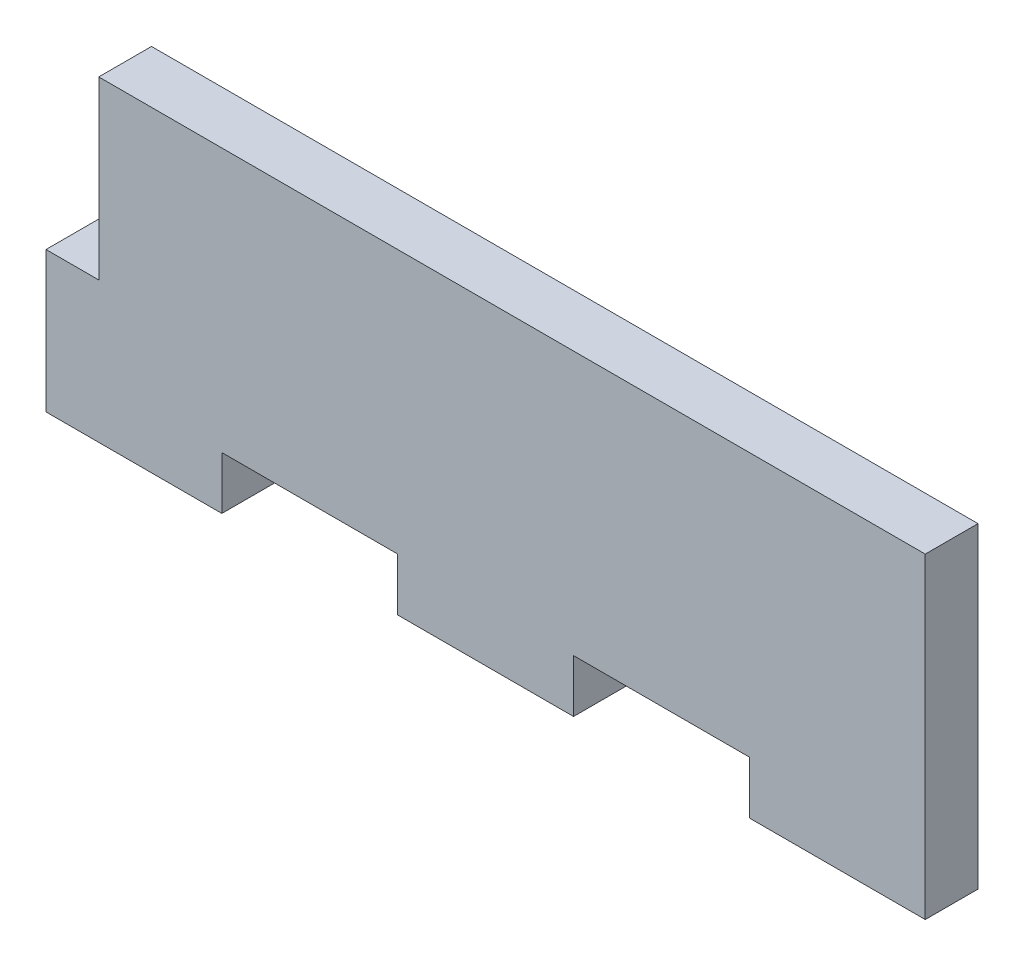
from build123d import *

# Parameters (mm, degrees)
ESQUISSE1_W                = 50
ESQUISSE1_H                = 18
BOSS_EXTRU_1_DEPTH         = 3
ESQUISSE2_W                = 10
ESQUISSE2_H                = 3
ENL_V_MAT_EXTRU_1_DEPTH    = 3
R_P_TITION_LIN_AIRE1_COUNT = 2
R_P_TITION_LIN_AIRE1_PITCH = 20
ESQUISSE3_W                = 3
ESQUISSE3_H                = 10
ENL_V_MAT_EXTRU_2_DEPTH    = 3


with BuildPart() as part:
    # Esquisse1 → Boss.-Extru.1 (new body)
    with BuildSketch(Plane.XY):
        with Locations((25, -9)):
            Rectangle(ESQUISSE1_W, ESQUISSE1_H)
    extrude(amount=BOSS_EXTRU_1_DEPTH)

    # Esquisse2 → Enlèv. mat.-Extru.1 (cut)
    with BuildSketch(Plane.XY.offset(3)):
        with Locations((35, -16.5)):
            Rectangle(ESQUISSE2_W, ESQUISSE2_H)
    enl_v_mat_extru_1 = extrude(amount=-ENL_V_MAT_EXTRU_1_DEPTH, mode=Mode.SUBTRACT)

    # Répétition linéaire1: Enlèv. mat.-Extru.1 ×2
    with Locations(*[(-i * R_P_TITION_LIN_AIRE1_PITCH, 0, 0) for i in range(1, R_P_TITION_LIN_AIRE1_COUNT)]):
        add(enl_v_mat_extru_1, mode=Mode.SUBTRACT)

    # Esquisse3 → Enlèv. mat.-Extru.2 (cut)
    with BuildSketch(Plane.XY.offset(3)):
        with Locations((1.5, -5)):
            Rectangle(ESQUISSE3_W, ESQUISSE3_H)
    extrude(amount=-ENL_V_MAT_EXTRU_2_DEPTH, mode=Mode.SUBTRACT)


solid = part.part
